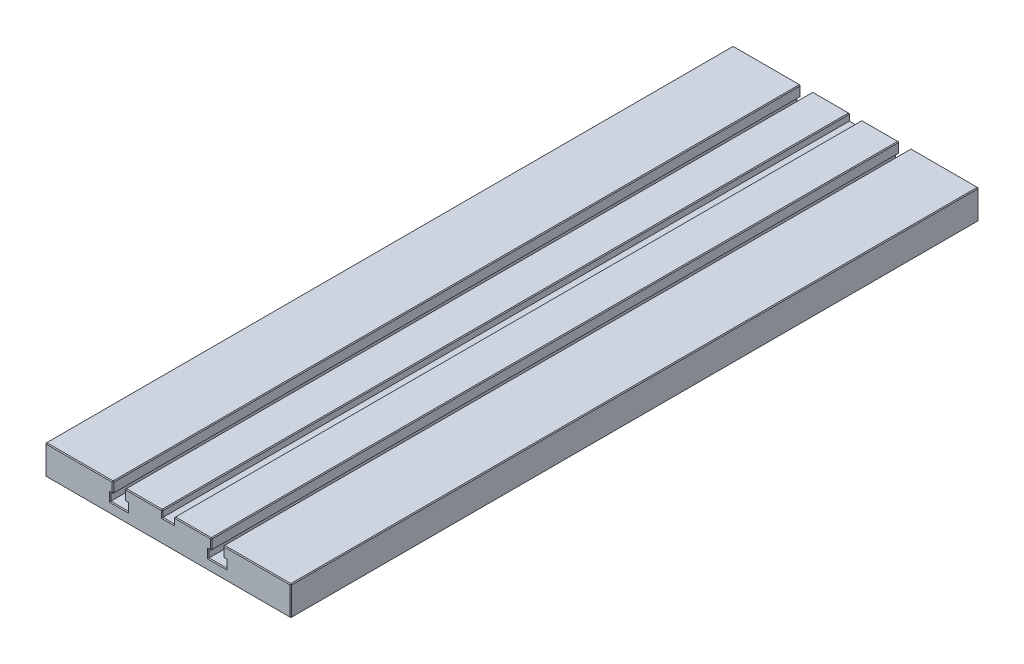
from build123d import *

# Parameters (mm, degrees)
CROQUIS1_W              = 250
CROQUIS1_H              = 30
SALIENTE_EXTRUIR1_DEPTH = 700
CROQUIS3_W              = 12
CROQUIS3_H              = 13.6
CORTAR_EXTRUIR1_DEPTH   = 794.2
CHAFL_N1_SIZE           = 0.8


with BuildPart() as part:
    # Croquis1 → Saliente-Extruir1 (new body)
    with BuildSketch(Plane.XY):
        Rectangle(CROQUIS1_W, CROQUIS1_H)
    extrude(amount=SALIENTE_EXTRUIR1_DEPTH)

    # Croquis3 → Cortar-Extruir1 (cut)
    with BuildSketch(Plane.XY.offset(700)):
        Polygon((-56, 15), (-56, 4.83), (-56.8, 4.03), (-59, 4.03), (-59, -3.97), (-41, -3.97), (-41, 4.03), (-43.2, 4.03), (-44, 4.83), (-44, 15), align=None)
        Polygon((41, -3.97), (41, 4.03), (43.2, 4.03), (44, 4.83), (44, 15), (56, 15), (56, 4.83), (56.8, 4.03), (59, 4.03), (59, -3.97), align=None)
        with Locations((0, 15)):
            Rectangle(CROQUIS3_W, CROQUIS3_H)
    extrude(amount=-CORTAR_EXTRUIR1_DEPTH, mode=Mode.SUBTRACT)

    # Chaflán1
    chafl_n1_edges = [part.edges().sort_by_distance(p)[0] for p in [
        (125, 0, 700),
        (90.5, 15, 700),
        (-90.5, 15, 0),
        (-56, 9.915, 0),
        (-56.4, 4.43, 0),
        (-57.9, 4.03, 0),
        (-59, 0.03, 0),
        (-50, -3.97, 0),
        (-41, 0.03, 0),
        (-42.1, 4.03, 0),
        (-43.6, 4.43, 0),
        (-44, 9.915, 0),
        (-90.5, 15, 700),
        (-56, 15, 350),
        (-44, 15, 350),
        (-56, 9.915, 700),
        (-56.4, 4.43, 700),
        (-57.9, 4.03, 700),
        (-59, 0.03, 700),
        (-50, -3.97, 700),
        (-41, 0.03, 700),
        (-42.1, 4.03, 700),
        (-43.6, 4.43, 700),
        (-44, 9.915, 700),
        (-125, 0, 700),
        (90.5, 15, 0),
        (125, 0, 0),
        (0, -15, 0),
        (25, 15, 0),
        (59, 0.03, 0),
        (57.9, 4.03, 0),
        (56.4, 4.43, 0),
        (56, 9.915, 0),
        (50, -3.97, 0),
        (41, 0.03, 0),
        (42.1, 4.03, 0),
        (43.6, 4.43, 0),
        (-125, 0, 0),
        (44, 9.915, 0),
        (25, 15, 700),
        (44, 15, 350),
        (56, 15, 350),
        (50, -3.97, 700),
        (59, 0.03, 700),
        (0, -15, 700),
        (57.9, 4.03, 700),
        (56.4, 4.43, 700),
        (56, 9.915, 700),
        (44, 9.915, 700),
        (43.6, 4.43, 700),
        (42.1, 4.03, 700),
        (41, 0.03, 700),
        (-125, 15, 350),
        (125, 15, 350),
        (125, -15, 350),
        (-125, -15, 350),
        (-25, 15, 0),
        (0, 8.2, 0),
        (6, 11.6, 0),
        (-6, 11.6, 0),
        (-25, 15, 700),
        (6, 11.6, 700),
        (-6, 11.6, 700),
        (0, 8.2, 700),
        (-6, 15, 350),
        (6, 15, 350),
    ]]
    chamfer(chafl_n1_edges, length=CHAFL_N1_SIZE)


solid = part.part
